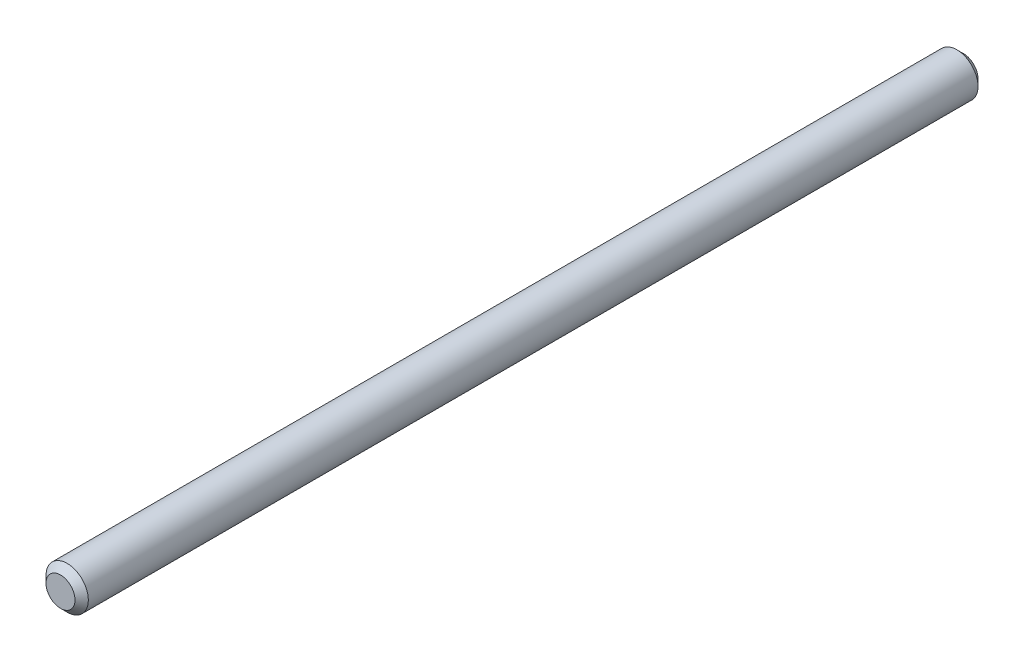
from build123d import *

# Parameters (mm, degrees)
SKETCH1_R           = 3.175
BOSS_EXTRUDE1_DEPTH = 135.470000078
CHAMFER1_SIZE       = 1


with BuildPart() as part:
    # Sketch1 → Boss-Extrude1 (new body)
    with BuildSketch(Plane.XY):
        Circle(SKETCH1_R)
    extrude(amount=-BOSS_EXTRUDE1_DEPTH)

    # Chamfer1
    chamfer1_edges = [part.edges().sort_by_distance(p)[0] for p in [
        (-3.175, 0, 0),
        (-3.175, 0, -135.470000078),
    ]]
    chamfer(chamfer1_edges, length=CHAMFER1_SIZE)


solid = part.part
